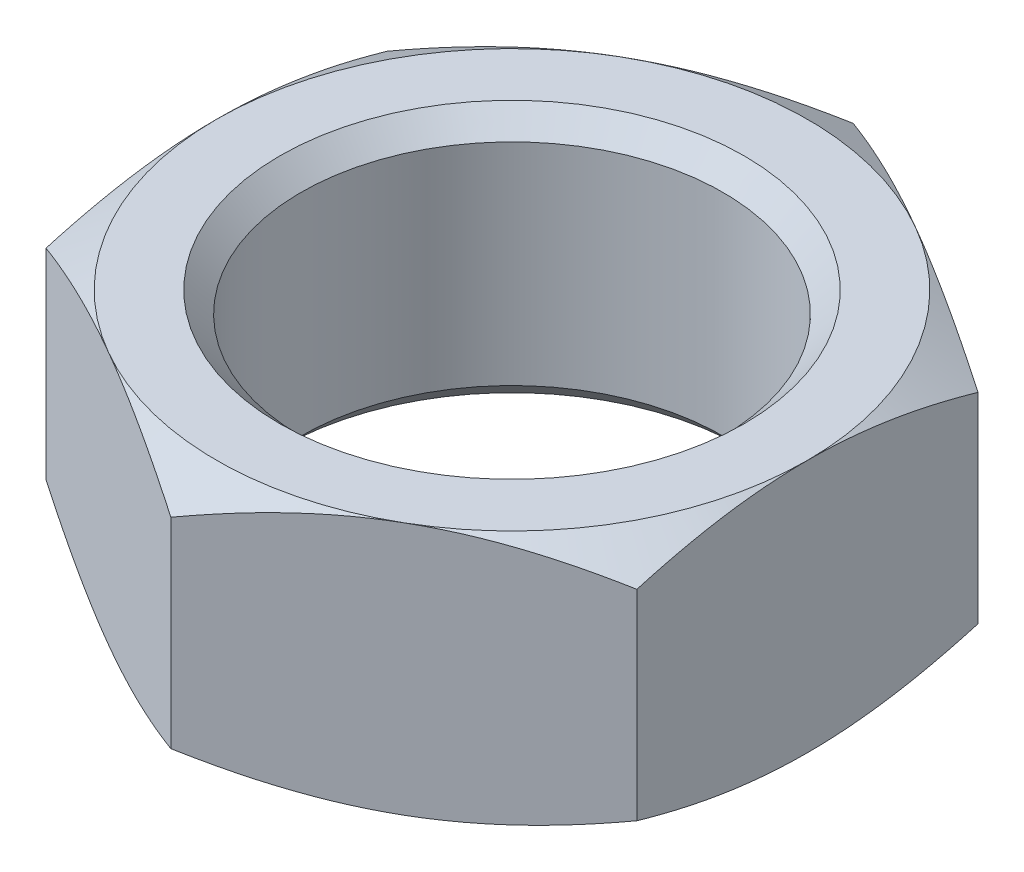
from build123d import *

# Parameters (mm, degrees)
BOSS_EXTRUDE1_DEPTH = 6
SKETCH2_OUTSIDE_W   = 80.454
SKETCH2_OUTSIDE_H   = 84.786
SKETCH2_OUTSIDE_R   = 14
CUT_EXTRUDE1_DEPTH  = 12
CUT_EXTRUDE1_TAPER  = 60
SKETCH3_R           = 10
CUT_EXTRUDE2_DEPTH  = 13
CHAMFER1_SIZE       = 1


with BuildPart() as part:
    # Sketch1 → Boss-Extrude1 (new body, symmetric)
    with BuildSketch(Plane(origin=(0, 0, 0), x_dir=(1, 0, 0), z_dir=(0, 1, 0))):
        Polygon((0, 16.165807537), (-14, 8.082903769), (-14, -8.082903769), (0, -16.165807537), (14, -8.082903769), (14, 8.082903769), align=None)
    extrude(amount=BOSS_EXTRUDE1_DEPTH, both=True)

    # Sketch2 outside → Cut-Extrude1 (cut)
    with BuildSketch(Plane(origin=(0, 6, 0), x_dir=(1, 0, 0), z_dir=(0, 1, 0))):
        Rectangle(SKETCH2_OUTSIDE_W, SKETCH2_OUTSIDE_H)
        Circle(SKETCH2_OUTSIDE_R, mode=Mode.SUBTRACT)
    cut_extrude1 = extrude(amount=-CUT_EXTRUDE1_DEPTH, taper=CUT_EXTRUDE1_TAPER, mode=Mode.SUBTRACT)

    # Mirror1: Cut-Extrude1 across plane
    add(cut_extrude1.mirror(Plane.ZX), mode=Mode.SUBTRACT)

    # Sketch3 → Cut-Extrude2 (cut, through all)
    with BuildSketch(Plane(origin=(0, 6, 0), x_dir=(1, 0, 0), z_dir=(0, 1, 0))):
        Circle(SKETCH3_R)
    extrude(amount=-CUT_EXTRUDE2_DEPTH, mode=Mode.SUBTRACT)

    # Chamfer1
    chamfer1_edges = [part.edges().sort_by_distance(p)[0] for p in [
        (-10, -6, 0),
        (-10, 6, 0),
    ]]
    chamfer(chamfer1_edges, length=CHAMFER1_SIZE)


solid = part.part
